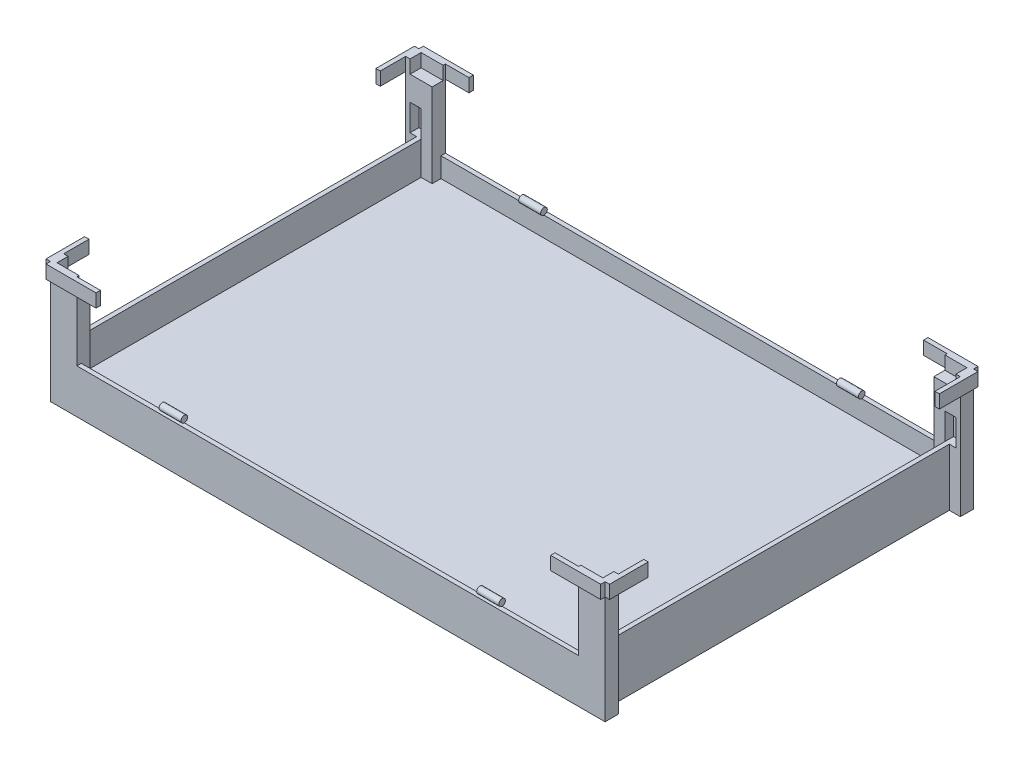
from build123d import *

# Parameters (mm, degrees)
SCHIZZO1_W                    = 1207
SCHIZZO1_H                    = 835
ESTRUSIONE_ESTRUSIONE2_DEPTH  = 100
SVUOTA1_T                     = -10
ESTRUSIONE_ESTRUSIONE3_REACH  = 837
SCHIZZO6_W                    = 1207
SCHIZZO6_H                    = 10
SCHIZZO12_W                   = 10
SCHIZZO12_H                   = 835
ESTRUSIONE_ESTRUSIONE10_DEPTH = 30
SCHIZZO7_W                    = 60
SCHIZZO7_H                    = 275
ESTRUSIONE_ESTRUSIONE4_DEPTH  = 10
SCHIZZO8_W                    = 20
SCHIZZO8_H                    = 145
ESTRUSIONE_ESTRUSIONE5_DEPTH  = 10
SCHIZZO9_W                    = 5
SCHIZZO9_H                    = 30
ESTRUSIONE_ESTRUSIONE6_DEPTH  = 75
SCHIZZO10_W                   = 5
SCHIZZO10_H                   = 30
ESTRUSIONE_ESTRUSIONE7_DEPTH  = 65
SCHIZZO11_W                   = 5
SCHIZZO11_H                   = 20
ESTRUSIONE_ESTRUSIONE8_DEPTH  = 25
SCHIZZO8_3_W                  = 20
SCHIZZO8_3_H                  = 130
ESTRUSIONE_ESTRUSIONE9_DEPTH  = 25
SCHIZZO14_W                   = 87.5
SCHIZZO14_H                   = 30
ESTRUSIONE_ESTRUSIONE12_DEPTH = 10
SCHIZZO15_W                   = 50
SCHIZZO15_H                   = 5
TAGLIO_ESTRUSIONE1_DEPTH      = 30
SCHIZZO16_W                   = 20
SCHIZZO16_H                   = 20
ESTRUSIONE_ESTRUSIONE13_DEPTH = 190
SCHIZZO17_W                   = 30
SCHIZZO17_H                   = 20
ESTRUSIONE_ESTRUSIONE14_DEPTH = 50
SCHIZZO18_W                   = 113.5
SCHIZZO18_H                   = 30
ESTRUSIONE_ESTRUSIONE15_DEPTH = 10
SPECCHIA2_COPY_1_SKETCH_W     = 60
SPECCHIA2_COPY_1_SKETCH_H     = 275
SPECCHIA2_COPY_1_DEPTH        = 10
SPECCHIA2_COPY_2_SKETCH_W     = 20
SPECCHIA2_COPY_2_SKETCH_H     = 145
SPECCHIA2_COPY_2_DEPTH        = 10
SPECCHIA2_COPY_3_SKETCH_W     = 5
SPECCHIA2_COPY_3_SKETCH_H     = 30
SPECCHIA2_COPY_3_DEPTH        = 75
SPECCHIA2_COPY_4_SKETCH_W     = 5
SPECCHIA2_COPY_4_SKETCH_H     = 30
SPECCHIA2_COPY_4_DEPTH        = 65
SPECCHIA2_COPY_5_SKETCH_W     = 5
SPECCHIA2_COPY_5_SKETCH_H     = 20
SPECCHIA2_COPY_5_DEPTH        = 25
SPECCHIA2_COPY_6_SKETCH_W     = 20
SPECCHIA2_COPY_6_SKETCH_H     = 130
SPECCHIA2_COPY_6_DEPTH        = 25
SPECCHIA2_COPY_7_SKETCH_W     = 87.5
SPECCHIA2_COPY_7_SKETCH_H     = 30
SPECCHIA2_COPY_7_DEPTH        = 10
SPECCHIA2_COPY_8_SKETCH_W     = 50
SPECCHIA2_COPY_8_SKETCH_H     = 5
SPECCHIA2_COPY_8_DEPTH        = 30
SPECCHIA2_COPY_9_SKETCH_W     = 20
SPECCHIA2_COPY_9_SKETCH_H     = 20
SPECCHIA2_COPY_9_DEPTH        = 190
SPECCHIA2_COPY_10_SKETCH_W    = 30
SPECCHIA2_COPY_10_SKETCH_H    = 20
SPECCHIA2_COPY_10_DEPTH       = 50
SPECCHIA2_COPY_11_SKETCH_W    = 113.5
SPECCHIA2_COPY_11_SKETCH_H    = 30
SPECCHIA2_COPY_11_DEPTH       = 10
SPECCHIA2_COPY_12_SKETCH_W    = 20
SPECCHIA2_COPY_12_SKETCH_H    = 130
SPECCHIA2_COPY_12_DEPTH       = 25
SPECCHIA2_COPY_13_SKETCH_W    = 30
SPECCHIA2_COPY_13_SKETCH_H    = 20
SPECCHIA2_COPY_13_DEPTH       = 50
ESTRUSIONE_ESTRUSIONE11_START = 233.5
SCHIZZO13_R                   = 7.5
ESTRUSIONE_ESTRUSIONE11_DEPTH = 50


with BuildPart() as part:
    # Schizzo1 → Estrusione-Estrusione2 (new body)
    with BuildSketch(Plane(origin=(0, 0, 0), x_dir=(1, 0, 0), z_dir=(0, 1, 0))):
        Rectangle(SCHIZZO1_W, SCHIZZO1_H)
    extrude(amount=ESTRUSIONE_ESTRUSIONE2_DEPTH)

    # Svuota1
    svuota1_openings = [part.faces().sort_by_distance(p)[0] for p in [
        (0, 100, 0),
        (0, 0, 0),
    ]]
    offset(amount=SVUOTA1_T, openings=svuota1_openings, kind=Kind.INTERSECTION)

    # Schizzo6 → Estrusione-Estrusione3 (add, up to next)
    with BuildSketch(Plane.XY.offset(417.5), mode=Mode.PRIVATE) as estrusione_estrusione3_sk1:
        with Locations((0, 50)):
            Rectangle(SCHIZZO6_W, SCHIZZO6_H)
    estrusione_estrusione3_tool1 = extrude(estrusione_estrusione3_sk1.sketch, amount=-ESTRUSIONE_ESTRUSIONE3_REACH, mode=Mode.PRIVATE) - part.part
    add(estrusione_estrusione3_tool1.solids().sort_by_distance((0, 50, 417.5))[0])

    # Schizzo12 → Estrusione-Estrusione10 (add)
    with BuildSketch(Plane(origin=(0, 100, 0), x_dir=(1, 0, 0), z_dir=(0, 1, 0))):
        with Locations((598.5, 0)):
            Rectangle(SCHIZZO12_W, SCHIZZO12_H)
        with Locations((-598.5, 0)):
            Rectangle(SCHIZZO12_W, SCHIZZO12_H)
    extrude(amount=ESTRUSIONE_ESTRUSIONE10_DEPTH)

    # Schizzo7 → Estrusione-Estrusione4 (add)
    with BuildSketch(Plane.XY.offset(417.5)):
        with Locations((598.5, 137.5)):
            Rectangle(SCHIZZO7_W, SCHIZZO7_H)
    estrusione_estrusione4 = extrude(amount=-ESTRUSIONE_ESTRUSIONE4_DEPTH)

    # Schizzo8 → Estrusione-Estrusione5 (add)
    with BuildSketch(Plane(origin=(628.5, 0, 0), x_dir=(0, 0, -1), z_dir=(1, 0, 0))):
        with Locations((-397.5, 202.5)):
            Rectangle(SCHIZZO8_W, SCHIZZO8_H)
    estrusione_estrusione5 = extrude(amount=-ESTRUSIONE_ESTRUSIONE5_DEPTH)

    # Schizzo9 → Estrusione-Estrusione6 (add)
    with BuildSketch(Plane(origin=(0, 130, 0), x_dir=(1, 0, 0), z_dir=(0, 1, 0))):
        with Locations((591, -402.5)):
            Rectangle(SCHIZZO9_W, SCHIZZO9_H)
    estrusione_estrusione6 = extrude(amount=-ESTRUSIONE_ESTRUSIONE6_DEPTH)

    # Schizzo10 → Estrusione-Estrusione7 (add)
    with BuildSketch(Plane(origin=(0, 130, 0), x_dir=(1, 0, 0), z_dir=(0, 1, 0))):
        with Locations((591, -402.5)):
            Rectangle(SCHIZZO10_W, SCHIZZO10_H)
    estrusione_estrusione7 = extrude(amount=ESTRUSIONE_ESTRUSIONE7_DEPTH)

    # Schizzo11 → Estrusione-Estrusione8 (add)
    with BuildSketch(Plane(origin=(593.5, -365, 0), x_dir=(0, 1, 0), z_dir=(-1, 0, 0))):
        with Locations((557.5, -397.5)):
            Rectangle(SCHIZZO11_W, SCHIZZO11_H)
    estrusione_estrusione8 = extrude(amount=-ESTRUSIONE_ESTRUSIONE8_DEPTH)

    # Schizzo8_3 → Estrusione-Estrusione9 (add)
    with BuildSketch(Plane(origin=(628.5, 0, 0), x_dir=(0, 0, -1), z_dir=(1, 0, 0))):
        with Locations((-397.5, 65)):
            Rectangle(SCHIZZO8_3_W, SCHIZZO8_3_H)
    estrusione_estrusione9 = extrude(amount=-ESTRUSIONE_ESTRUSIONE9_DEPTH)

    # Schizzo14 → Estrusione-Estrusione12 (add)
    with BuildSketch(Plane(origin=(628.5, 0, 0), x_dir=(0, 0, -1), z_dir=(1, 0, 0))):
        with Locations((-373.75, 260)):
            Rectangle(SCHIZZO14_W, SCHIZZO14_H)
    estrusione_estrusione12 = extrude(amount=ESTRUSIONE_ESTRUSIONE12_DEPTH)

    # Schizzo15 → Taglio-Estrusione1 (cut)
    with BuildSketch(Plane(origin=(0, 275, 0), x_dir=(1, 0, 0), z_dir=(0, 1, 0))):
        with Locations((593.5, -410)):
            Rectangle(SCHIZZO15_W, SCHIZZO15_H)
    taglio_estrusione1 = extrude(amount=-TAGLIO_ESTRUSIONE1_DEPTH, mode=Mode.SUBTRACT)

    # Schizzo16 → Estrusione-Estrusione13 (add)
    with BuildSketch(Plane(origin=(0, 55, 0), x_dir=(1, 0, 0), z_dir=(0, 1, 0))):
        with Locations((578.5, -397.5)):
            Rectangle(SCHIZZO16_W, SCHIZZO16_H)
    estrusione_estrusione13 = extrude(amount=ESTRUSIONE_ESTRUSIONE13_DEPTH)

    # Schizzo17 → Estrusione-Estrusione14 (add)
    with BuildSketch(Plane(origin=(0, 195, 0), x_dir=(1, 0, 0), z_dir=(0, 1, 0))):
        with Locations((603.5, -397.5)):
            Rectangle(SCHIZZO17_W, SCHIZZO17_H)
    estrusione_estrusione14 = extrude(amount=ESTRUSIONE_ESTRUSIONE14_DEPTH)

    # Schizzo18 → Estrusione-Estrusione15 (add)
    with BuildSketch(Plane.XY.offset(417.5)):
        with Locations((571.75, 260)):
            Rectangle(SCHIZZO18_W, SCHIZZO18_H)
    estrusione_estrusione15 = extrude(amount=ESTRUSIONE_ESTRUSIONE15_DEPTH)

    # Specchia1: Estrusione-Estrusione4, Estrusione-Estrusione5, Estrusione-Estrusione6, Estrusione-Estrusione7, Estrusione-Estrusione8, Estrusione-Estrusione9, Estrusione-Estrusione12, Taglio-Estrusione1, Estrusione-Estrusione13, Estrusione-Estrusione14, Estrusione-Estrusione15 across plane
    add(estrusione_estrusione4.mirror(Plane.XY))
    add(estrusione_estrusione5.mirror(Plane.XY))
    add(estrusione_estrusione6.mirror(Plane.XY))
    add(estrusione_estrusione7.mirror(Plane.XY))
    add(estrusione_estrusione8.mirror(Plane.XY))
    add(estrusione_estrusione9.mirror(Plane.XY))
    add(estrusione_estrusione12.mirror(Plane.XY))
    add(taglio_estrusione1.mirror(Plane.XY), mode=Mode.SUBTRACT)
    add(estrusione_estrusione13.mirror(Plane.XY))
    add(estrusione_estrusione14.mirror(Plane.XY))
    add(estrusione_estrusione15.mirror(Plane.XY))

    # Specchia2: Estrusione-Estrusione4, Estrusione-Estrusione5, Estrusione-Estrusione6, Estrusione-Estrusione7, Estrusione-Estrusione8, Estrusione-Estrusione12, Taglio-Estrusione1, Estrusione-Estrusione13, Estrusione-Estrusione15 across plane
    add(estrusione_estrusione4.mirror(Plane(origin=(0, 0, 0), x_dir=(0, 0, 1), z_dir=(1, 0, 0))))
    add(estrusione_estrusione5.mirror(Plane(origin=(0, 0, 0), x_dir=(0, 0, 1), z_dir=(1, 0, 0))))
    add(estrusione_estrusione6.mirror(Plane(origin=(0, 0, 0), x_dir=(0, 0, 1), z_dir=(1, 0, 0))))
    add(estrusione_estrusione7.mirror(Plane(origin=(0, 0, 0), x_dir=(0, 0, 1), z_dir=(1, 0, 0))))
    add(estrusione_estrusione8.mirror(Plane(origin=(0, 0, 0), x_dir=(0, 0, 1), z_dir=(1, 0, 0))))
    add(estrusione_estrusione12.mirror(Plane(origin=(0, 0, 0), x_dir=(0, 0, 1), z_dir=(1, 0, 0))))
    add(taglio_estrusione1.mirror(Plane(origin=(0, 0, 0), x_dir=(0, 0, 1), z_dir=(1, 0, 0))), mode=Mode.SUBTRACT)
    add(estrusione_estrusione13.mirror(Plane(origin=(0, 0, 0), x_dir=(0, 0, 1), z_dir=(1, 0, 0))))
    add(estrusione_estrusione15.mirror(Plane(origin=(0, 0, 0), x_dir=(0, 0, 1), z_dir=(1, 0, 0))))

    # Specchia2 copy 1 sketch → Specchia2 copy 1 (add)
    with BuildSketch(Plane(origin=(0, 0, -417.5), x_dir=(-1, 0, 0), z_dir=(0, 0, -1))):
        with Locations((598.5, 137.5)):
            Rectangle(SPECCHIA2_COPY_1_SKETCH_W, SPECCHIA2_COPY_1_SKETCH_H)
    extrude(amount=-SPECCHIA2_COPY_1_DEPTH)

    # Specchia2 copy 2 sketch → Specchia2 copy 2 (add)
    with BuildSketch(Plane.ZY.offset(628.5)):
        with Locations((-397.5, 202.5)):
            Rectangle(SPECCHIA2_COPY_2_SKETCH_W, SPECCHIA2_COPY_2_SKETCH_H)
    extrude(amount=-SPECCHIA2_COPY_2_DEPTH)

    # Specchia2 copy 3 sketch → Specchia2 copy 3 (add)
    with BuildSketch(Plane(origin=(0, 130, 0), x_dir=(-1, 0, 0), z_dir=(0, 1, 0))):
        with Locations((591, -402.5)):
            Rectangle(SPECCHIA2_COPY_3_SKETCH_W, SPECCHIA2_COPY_3_SKETCH_H)
    extrude(amount=-SPECCHIA2_COPY_3_DEPTH)

    # Specchia2 copy 4 sketch → Specchia2 copy 4 (add)
    with BuildSketch(Plane(origin=(0, 130, 0), x_dir=(-1, 0, 0), z_dir=(0, 1, 0))):
        with Locations((591, -402.5)):
            Rectangle(SPECCHIA2_COPY_4_SKETCH_W, SPECCHIA2_COPY_4_SKETCH_H)
    extrude(amount=SPECCHIA2_COPY_4_DEPTH)

    # Specchia2 copy 5 sketch → Specchia2 copy 5 (add)
    with BuildSketch(Plane(origin=(-593.5, -365, 0), x_dir=(0, 1, 0), z_dir=(1, 0, 0))):
        with Locations((557.5, -397.5)):
            Rectangle(SPECCHIA2_COPY_5_SKETCH_W, SPECCHIA2_COPY_5_SKETCH_H)
    extrude(amount=-SPECCHIA2_COPY_5_DEPTH)

    # Specchia2 copy 6 sketch → Specchia2 copy 6 (add)
    with BuildSketch(Plane.ZY.offset(628.5)):
        with Locations((-397.5, 65)):
            Rectangle(SPECCHIA2_COPY_6_SKETCH_W, SPECCHIA2_COPY_6_SKETCH_H)
    extrude(amount=-SPECCHIA2_COPY_6_DEPTH)

    # Specchia2 copy 7 sketch → Specchia2 copy 7 (add)
    with BuildSketch(Plane.ZY.offset(628.5)):
        with Locations((-373.75, 260)):
            Rectangle(SPECCHIA2_COPY_7_SKETCH_W, SPECCHIA2_COPY_7_SKETCH_H)
    extrude(amount=SPECCHIA2_COPY_7_DEPTH)

    # Specchia2 copy 8 sketch → Specchia2 copy 8 (cut)
    with BuildSketch(Plane(origin=(0, 275, 0), x_dir=(-1, 0, 0), z_dir=(0, 1, 0))):
        with Locations((593.5, -410)):
            Rectangle(SPECCHIA2_COPY_8_SKETCH_W, SPECCHIA2_COPY_8_SKETCH_H)
    extrude(amount=-SPECCHIA2_COPY_8_DEPTH, mode=Mode.SUBTRACT)

    # Specchia2 copy 9 sketch → Specchia2 copy 9 (add)
    with BuildSketch(Plane(origin=(0, 55, 0), x_dir=(-1, 0, 0), z_dir=(0, 1, 0))):
        with Locations((578.5, -397.5)):
            Rectangle(SPECCHIA2_COPY_9_SKETCH_W, SPECCHIA2_COPY_9_SKETCH_H)
    extrude(amount=SPECCHIA2_COPY_9_DEPTH)

    # Specchia2 copy 10 sketch → Specchia2 copy 10 (add)
    with BuildSketch(Plane(origin=(0, 195, 0), x_dir=(-1, 0, 0), z_dir=(0, 1, 0))):
        with Locations((603.5, -397.5)):
            Rectangle(SPECCHIA2_COPY_10_SKETCH_W, SPECCHIA2_COPY_10_SKETCH_H)
    extrude(amount=SPECCHIA2_COPY_10_DEPTH)

    # Specchia2 copy 11 sketch → Specchia2 copy 11 (add)
    with BuildSketch(Plane(origin=(0, 0, -417.5), x_dir=(-1, 0, 0), z_dir=(0, 0, -1))):
        with Locations((571.75, 260)):
            Rectangle(SPECCHIA2_COPY_11_SKETCH_W, SPECCHIA2_COPY_11_SKETCH_H)
    extrude(amount=SPECCHIA2_COPY_11_DEPTH)

    # Specchia2 copy 12 sketch → Specchia2 copy 12 (add)
    with BuildSketch(Plane(origin=(-628.5, 0, 0), x_dir=(0, 0, -1), z_dir=(-1, 0, 0))):
        with Locations((-397.5, -65)):
            Rectangle(SPECCHIA2_COPY_12_SKETCH_W, SPECCHIA2_COPY_12_SKETCH_H)
    extrude(amount=-SPECCHIA2_COPY_12_DEPTH)

    # Specchia2 copy 13 sketch → Specchia2 copy 13 (add)
    with BuildSketch(Plane(origin=(0, 195, 0), x_dir=(-1, 0, 0), z_dir=(0, 1, 0))):
        with Locations((603.5, 397.5)):
            Rectangle(SPECCHIA2_COPY_13_SKETCH_W, SPECCHIA2_COPY_13_SKETCH_H)
    extrude(amount=SPECCHIA2_COPY_13_DEPTH)


with BuildPart() as body_2:
    # Schizzo13 → Estrusione-Estrusione11 (new body)
    with BuildSketch(Plane.ZY.offset(-568.5).offset(ESTRUSIONE_ESTRUSIONE11_START)):
        with Locations((-407.5, 107.5)):
            Circle(SCHIZZO13_R)
    extrude(amount=-ESTRUSIONE_ESTRUSIONE11_DEPTH)


with BuildPart() as body_3:
    # Specchia3: mirrored copy
    add(body_2.part.mirror(Plane(origin=(0, 0, 0), x_dir=(0, 0, 1), z_dir=(1, 0, 0))))


with BuildPart() as body_4:
    # Specchia4: mirrored copy
    add(body_3.part.mirror(Plane.XY))


with BuildPart() as body_5:
    # Specchia4 2: mirrored copy
    add(body_2.part.mirror(Plane.XY))


solid = Compound([part.part, body_2.part, body_3.part, body_4.part, body_5.part])
